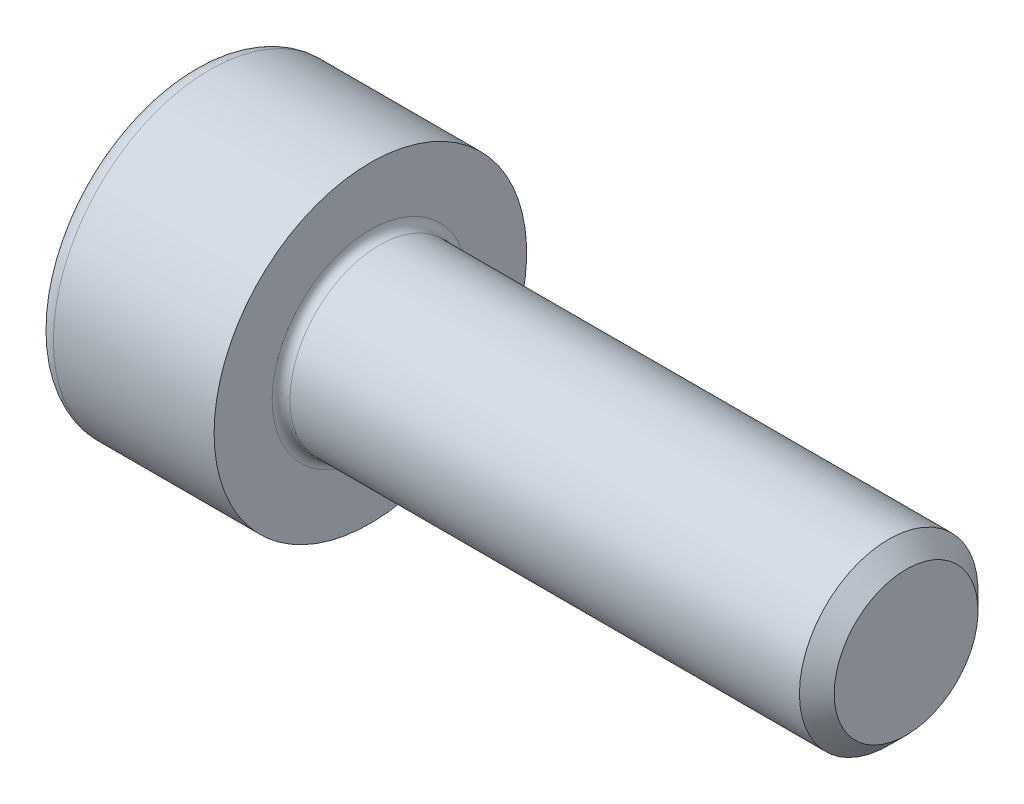
from build123d import *

# Parameters (mm, degrees)
FILLET1_R   = 0.2
FILLET2_R   = 0.4
HEX_2_DEPTH = 2


with BuildPart() as part:
    # BodySke → Base-Revolve (revolve)
    with BuildSketch(Plane.XY):
        Polygon((0, 0), (0, 3.5), (4, 3.5), (4, 2), (15.61, 2), (16, 1.61), (16, 0), align=None)
    revolve(axis=Axis((-31.75, 0, 0), (1, 0, 0)))

    # Fillet1
    fillet1_edges = [part.edges().sort_by_distance(p)[0] for p in [
        (4, -2, 0),
    ]]
    fillet(fillet1_edges, radius=FILLET1_R)

    # Fillet2
    fillet2_edges = [part.edges().sort_by_distance(p)[0] for p in [
        (0, -3.5, 0),
    ]]
    fillet(fillet2_edges, radius=FILLET2_R)

    # Sketch2 → Hex-PreBroach (revolve, cut)
    with BuildSketch(Plane.XY):
        Polygon((0, 1.51), (2, 1.51), (2.871798906, 0), (0, 0), align=None)
    revolve(axis=Axis((0, 0, 0), (1, 0, 0)), mode=Mode.SUBTRACT)

    # Sketch3 → Hex 2 (cut)
    with BuildSketch(Plane(origin=(0, 0, 0), x_dir=(0, 0.5, 0.866025404), z_dir=(-1, 0, 0))):
        Polygon((0.871798906, 1.51), (-0.871798906, 1.51), (-1.743597813, 0), (-0.871798906, -1.51), (0.871798906, -1.51), (1.743597813, 0), align=None)
    extrude(amount=-HEX_2_DEPTH, mode=Mode.SUBTRACT)


solid = part.part
